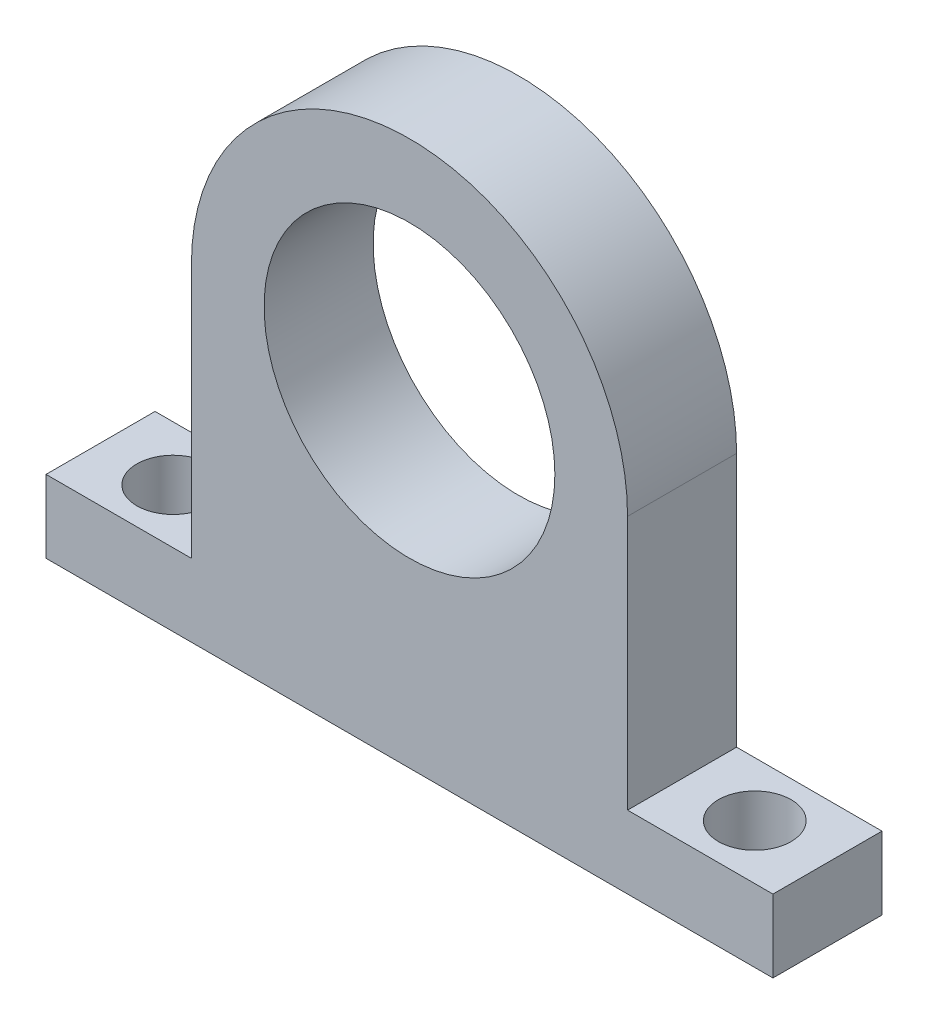
from build123d import *

# Parameters (mm, degrees)
SKETCH1_W           = 20
SKETCH1_H           = 2
BOSS_EXTRUDE1_DEPTH = 3
SKETCH2_R           = 1
CUT_EXTRUDE1_DEPTH  = 16


with BuildPart() as part:
    # Sketch1 → Boss-Extrude1 (new body)
    with BuildSketch(Plane.XY):
        with Locations((0, 1)):
            Rectangle(SKETCH1_W, SKETCH1_H)
        with BuildLine():
            Line((-6, 9), (-6, 2))
            Line((-6, 2), (6, 2))
            Line((6, 2), (6, 9))
            ThreePointArc((6, 9), (0, 3), (-6, 9))
        make_face()
        with BuildLine():
            ThreePointArc((6, 9), (0, 15), (-6, 9))
            Line((-6, 9), (-4, 9))
            ThreePointArc((-4, 9), (0, 13), (4, 9))
            Line((4, 9), (6, 9))
        make_face()
        with BuildLine():
            Line((-4, 9), (-6, 9))
            ThreePointArc((-6, 9), (0, 3), (6, 9))
            Line((6, 9), (4, 9))
            ThreePointArc((4, 9), (0, 5), (-4, 9))
        make_face()
    extrude(amount=BOSS_EXTRUDE1_DEPTH)

    # Sketch2 → Cut-Extrude1 (cut, through all)
    with BuildSketch(Plane(origin=(0, 0, 0), x_dir=(1, 0, 0), z_dir=(0, 1, 0))):
        with Locations((-8, -1.5)):
            Circle(SKETCH2_R)
        with Locations((8, -1.5)):
            Circle(SKETCH2_R)
    extrude(amount=CUT_EXTRUDE1_DEPTH, mode=Mode.SUBTRACT)


solid = part.part
